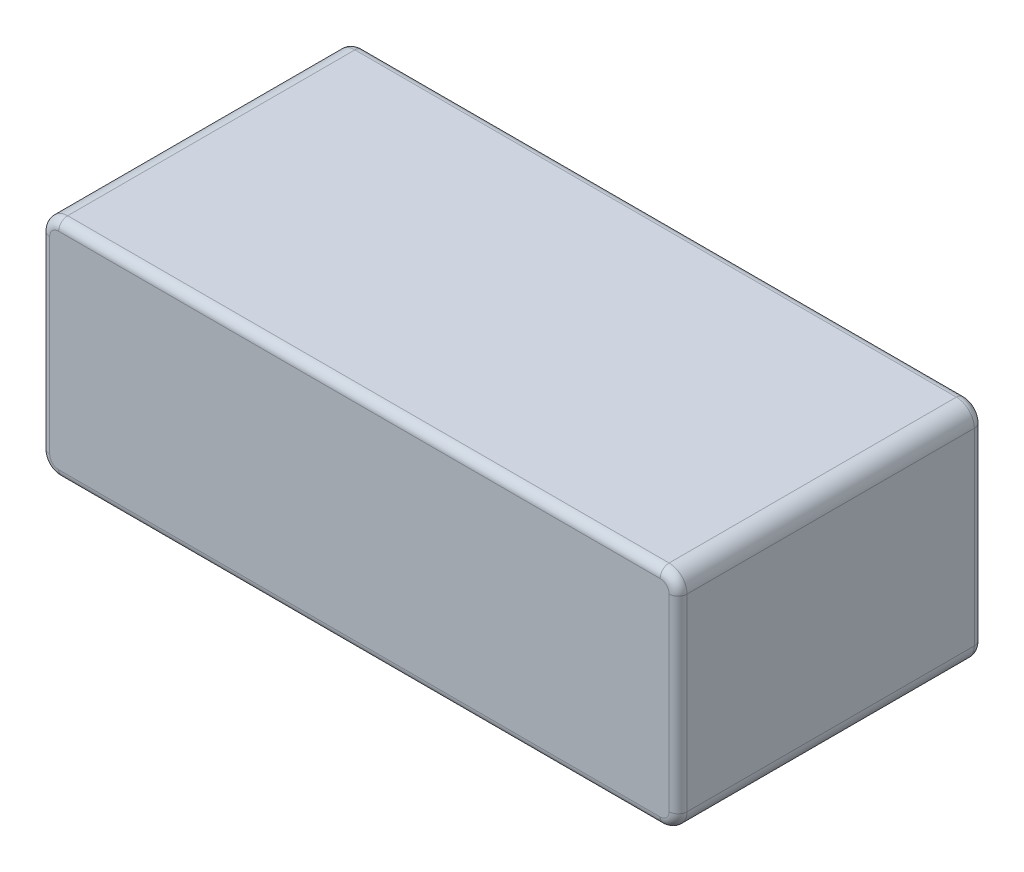
from build123d import *

# Parameters (mm, degrees)
SKIZZE1_W                       = 71
SKIZZE1_H                       = 25
AUFSATZ_LINEAR_AUSTRAGEN1_DEPTH = 34
VERRUNDUNG2_R                   = 2
VERRUNDUNG3_R                   = 2
VERRUNDUNG4_R                   = 2
VERRUNDUNG5_R                   = 2
VERRUNDUNG6_R                   = 1
VERRUNDUNG7_R                   = 1


with BuildPart() as part:
    # Skizze1 → Aufsatz-Linear austragen1 (new body)
    with BuildSketch(Plane.XY):
        with Locations((35.5, 12.5)):
            Rectangle(SKIZZE1_W, SKIZZE1_H)
    extrude(amount=AUFSATZ_LINEAR_AUSTRAGEN1_DEPTH)

    # Verrundung2
    verrundung2_edges = [part.edges().sort_by_distance(p)[0] for p in [
        (71, 25, 17),
    ]]
    fillet(verrundung2_edges, radius=VERRUNDUNG2_R)

    # Verrundung3
    verrundung3_edges = [part.edges().sort_by_distance(p)[0] for p in [
        (71, 0, 17),
    ]]
    fillet(verrundung3_edges, radius=VERRUNDUNG3_R)

    # Verrundung4
    verrundung4_edges = [part.edges().sort_by_distance(p)[0] for p in [
        (0, 25, 17),
    ]]
    fillet(verrundung4_edges, radius=VERRUNDUNG4_R)

    # Verrundung5
    verrundung5_edges = [part.edges().sort_by_distance(p)[0] for p in [
        (0, 0, 17),
    ]]
    fillet(verrundung5_edges, radius=VERRUNDUNG5_R)

    # Verrundung6
    verrundung6_edges = [part.edges().sort_by_distance(p)[0] for p in [
        (35.5, 25, 34),
        (70.414213562, 24.414213562, 34),
        (71, 12.5, 34),
        (70.414213562, 0.585786438, 34),
        (0, 12.5, 34),
        (0.585786438, 24.414213562, 34),
        (35.5, 0, 34),
        (0.585786438, 0.585786438, 34),
    ]]
    fillet(verrundung6_edges, radius=VERRUNDUNG6_R)

    # Verrundung7
    verrundung7_edges = [part.edges().sort_by_distance(p)[0] for p in [
        (35.5, 25, 0),
        (70.414213562, 24.414213562, 0),
        (71, 12.5, 0),
        (70.414213562, 0.585786438, 0),
        (0, 12.5, 0),
        (0.585786438, 24.414213562, 0),
        (35.5, 0, 0),
        (0.585786438, 0.585786438, 0),
    ]]
    fillet(verrundung7_edges, radius=VERRUNDUNG7_R)


solid = part.part
